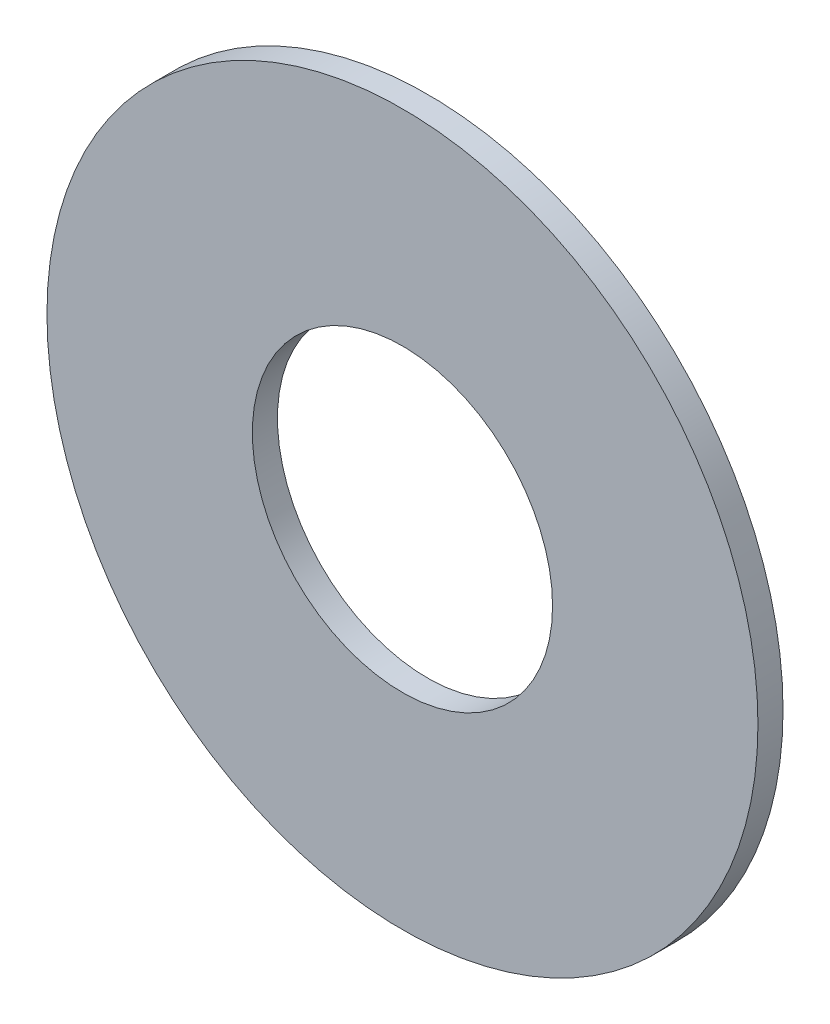
from build123d import *

# Parameters (mm, degrees)
SKETCH1_R           = 11.25
SKETCH1_R_2         = 4.75
BOSS_EXTRUDE1_DEPTH = 0.79375


with BuildPart() as part:
    # Sketch1 → Boss-Extrude1 (new body)
    with BuildSketch(Plane.XY):
        Circle(SKETCH1_R)
        Circle(SKETCH1_R_2, mode=Mode.SUBTRACT)
    extrude(amount=BOSS_EXTRUDE1_DEPTH)


solid = part.part
